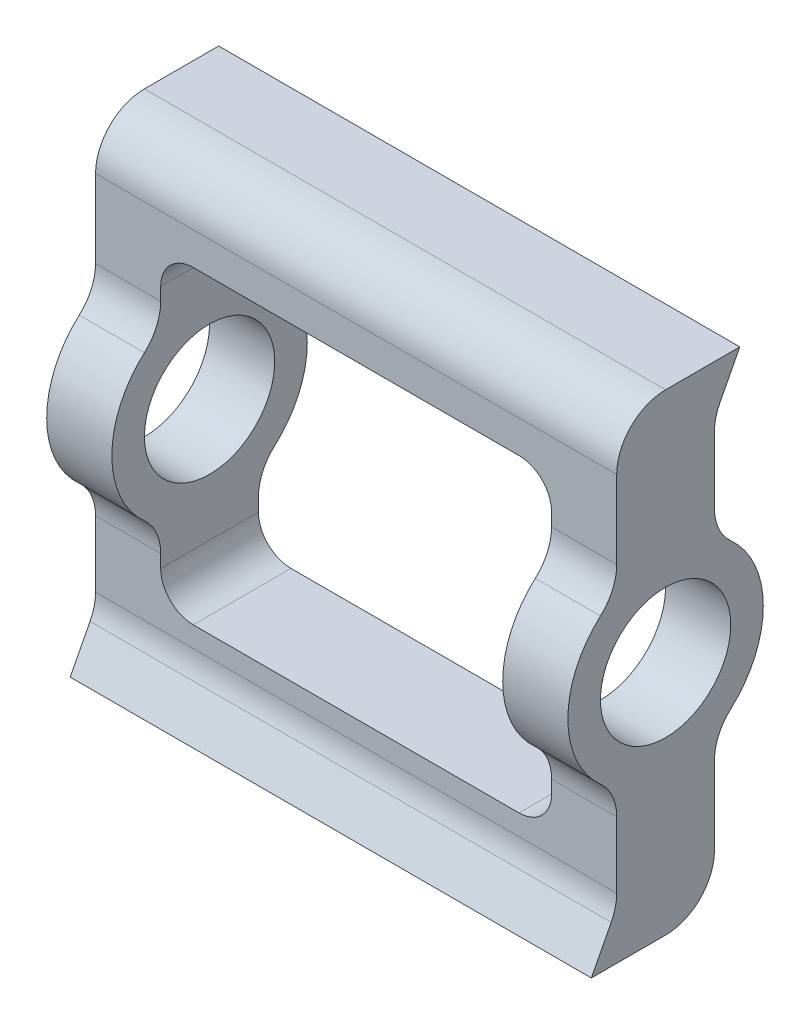
from build123d import *

# Parameters (mm, degrees)
SKETCH1_R               = 12.7
BOSS_EXTRUDE1_DEPTH     = 50.8
SKETCH2_W               = 76.2
SKETCH2_H               = 60.325
CUT_EXTRUDE1_DEPTH      = 20.05
CUT_EXTRUDE1_DEPTH_BACK = 20.05
FILLET1_R               = 6.35
FILLET2_R               = 9.525
FILLET3_R               = 9.525
FILLET4_R               = 9.525


with BuildPart() as part:
    # Sketch1 → Boss-Extrude1 (new body, symmetric)
    with BuildSketch(Plane(origin=(0, 0, 0), x_dir=(0, 0, -1), z_dir=(1, 0, 0))):
        with BuildLine():
            Line((9.525, 36.5125), (14.473290811, 46.0375))
            Line((14.473290811, 46.0375), (-9.525, 46.0375))
            Line((-9.525, 46.0375), (-9.525, 36.5125))
            Line((-9.525, 36.5125), (-9.525, 16.497783942))
            ThreePointArc((-9.525, 16.497783942), (-19.05, 0), (-9.525, -16.497783942))
            Line((-9.525, -16.497783942), (-9.525, -36.5125))
            Line((-9.525, -36.5125), (-14.473290811, -46.0375))
            Line((-14.473290811, -46.0375), (9.525, -46.0375))
            Line((9.525, -46.0375), (9.525, -36.5125))
            Line((9.525, -36.5125), (9.525, -16.497783942))
            ThreePointArc((9.525, -16.497783942), (19.05, 0), (9.525, 16.497783942))
            Line((9.525, 16.497783942), (9.525, 36.5125))
        make_face()
        Circle(SKETCH1_R, mode=Mode.SUBTRACT)
    extrude(amount=BOSS_EXTRUDE1_DEPTH, both=True)

    # Sketch2 → Cut-Extrude1 (cut, two sides)
    with BuildSketch(Plane.XY) as cut_extrude1_sk:
        Rectangle(SKETCH2_W, SKETCH2_H)
    extrude(amount=CUT_EXTRUDE1_DEPTH, mode=Mode.SUBTRACT)
    extrude(cut_extrude1_sk.sketch, amount=-CUT_EXTRUDE1_DEPTH_BACK, mode=Mode.SUBTRACT)

    # Fillet1
    fillet1_edges = [part.edges().sort_by_distance(p)[0] for p in [
        (-38.1, 30.1625, 0),
        (38.1, -30.1625, 0),
        (38.1, 30.1625, 0),
        (-38.1, -30.1625, 0),
    ]]
    fillet(fillet1_edges, radius=FILLET1_R)

    # Fillet2
    fillet2_edges = [part.edges().sort_by_distance(p)[0] for p in [
        (44.45, 16.497783942, -9.525),
        (44.45, -16.497783942, -9.525),
        (44.45, -16.497783942, 9.525),
        (44.45, 16.497783942, 9.525),
        (-44.45, 16.497783942, -9.525),
        (-44.45, -16.497783942, -9.525),
        (-44.45, -16.497783942, 9.525),
        (-44.45, 16.497783942, 9.525),
    ]]
    fillet(fillet2_edges, radius=FILLET2_R)

    # Fillet3
    fillet3_edges = [part.edges().sort_by_distance(p)[0] for p in [
        (0, -46.0375, -9.525),
        (0, 46.0375, 9.525),
    ]]
    fillet(fillet3_edges, radius=FILLET3_R)

    # Fillet4
    fillet4_edges = [part.edges().sort_by_distance(p)[0] for p in [
        (0, -36.5125, 9.525),
        (0, 36.5125, -9.525),
    ]]
    fillet(fillet4_edges, radius=FILLET4_R)


solid = part.part
